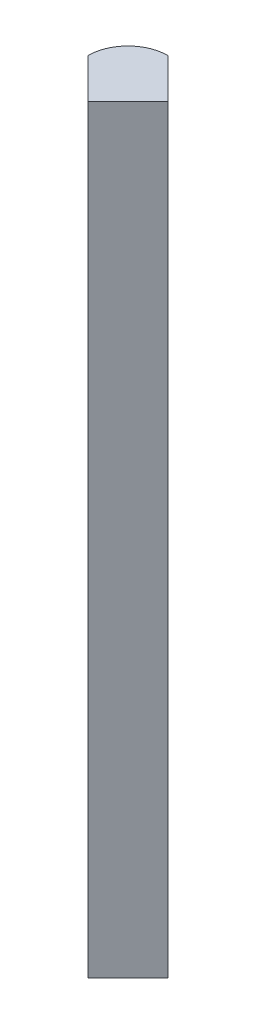
from build123d import *

# Parameters (mm, degrees)
BOSS_EXTRUDE2_DEPTH = 76.2


with BuildPart() as part:
    # Sketch1 → Boss-Extrude2 (new body)
    with BuildSketch(Plane(origin=(0, 0, 0), x_dir=(1, 0, 0), z_dir=(0, 1, 0))):
        with BuildLine():
            Line((-3.999997523, 0.00445124), (2.477e-06, -3.995548761))
            Line((2.477e-06, -3.995548761), (4, 0.004448763))
            Line((4, 0.004448763), (0.00445124, 3.999997523))
            ThreePointArc((0.00445124, 3.999997523), (-2.825277872, 2.831572875), (-3.999997523, 0.00445124))
        make_face()
    extrude(amount=BOSS_EXTRUDE2_DEPTH)


solid = part.part
